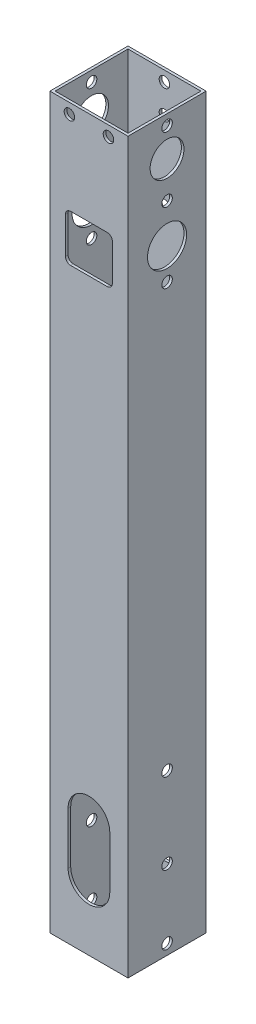
from build123d import *

# Parameters (mm, degrees)
SKETCH_1_W               = 30
SKETCH_1_H               = 30
EXTRUDE_1_DEPTH          = 140
SKETCH_2_W               = 28
SKETCH_2_H               = 28
CUT_EXTRUDE_1_DEPTH      = 141
CUT_EXTRUDE_1_DEPTH_BACK = 141
SKETCH_3_R               = 2.025
CUT_EXTRUDE_2_DEPTH      = 1
CUT_EXTRUDE_2_DEPTH_BACK = 31
SKETCH_5_R               = 2.025
CUT_EXTRUDE_3_DEPTH      = 31
SKETCH_6_R               = 2.025
CUT_EXTRUDE_4_DEPTH      = 1
SKETCH_7_W               = 18
SKETCH_7_H               = 18
CUT_EXTRUDE_5_DEPTH      = 1
FILLET_1_R               = 2
SKETCH_8_R               = 2.025
CUT_EXTRUDE_6_DEPTH      = 10
SKETCH_10_R              = 7.5
SKETCH_10_R_2            = 6.5
CUT_EXTRUDE_7_DEPTH      = 1
CUT_EXTRUDE_7_DEPTH_BACK = 31
CUT_EXTRUDE_8_DEPTH      = 1
CUT_EXTRUDE_8_DEPTH_BACK = 31
CUT_EXTRUDE_START        = 29
SKETCH_12_R              = 2.025
CUT_EXTRUDE_9_DEPTH      = 10


with BuildPart() as part:
    # 草图1 → 凸台-拉伸1 (new body, symmetric)
    with BuildSketch(Plane(origin=(0, 0, 0), x_dir=(1, 0, 0), z_dir=(0, 1, 0))):
        Rectangle(SKETCH_1_W, SKETCH_1_H)
    extrude(amount=EXTRUDE_1_DEPTH, both=True)

    # 草图2 → 切除-拉伸1 (cut, two sides)
    with BuildSketch(Plane(origin=(0, 0, 0), x_dir=(1, 0, 0), z_dir=(0, 1, 0))) as cut_extrude_1_sk:
        Rectangle(SKETCH_2_W, SKETCH_2_H)
    extrude(amount=CUT_EXTRUDE_1_DEPTH, mode=Mode.SUBTRACT)
    extrude(cut_extrude_1_sk.sketch, amount=-CUT_EXTRUDE_1_DEPTH_BACK, mode=Mode.SUBTRACT)

    # 草图3 → 切除-拉伸2 (cut, two sides)
    with BuildSketch(Plane.ZY.offset(15)) as cut_extrude_2_sk:
        with Locations((0, -78.5)):
            Circle(SKETCH_3_R)
        with Locations((0, -109.5)):
            Circle(SKETCH_3_R)
        with Locations((0, -136)):
            Circle(SKETCH_3_R)
    extrude(amount=CUT_EXTRUDE_2_DEPTH, mode=Mode.SUBTRACT)
    extrude(cut_extrude_2_sk.sketch, amount=-CUT_EXTRUDE_2_DEPTH_BACK, mode=Mode.SUBTRACT)

    # 草图5 → 切除-拉伸3 (cut, through all)
    with BuildSketch(Plane.ZY.offset(15)):
        with Locations((0, 136)):
            Circle(SKETCH_5_R)
        with Locations((0, 111)):
            Circle(SKETCH_5_R)
        with Locations((0, 84)):
            Circle(SKETCH_5_R)
    extrude(amount=-CUT_EXTRUDE_3_DEPTH, mode=Mode.SUBTRACT)

    # 草图6 → 切除-拉伸4 (cut)
    with BuildSketch(Plane(origin=(0, 0, -15), x_dir=(-1, 0, 0), z_dir=(0, 0, -1))):
        with Locations((0, 95)):
            Circle(SKETCH_6_R)
        with Locations((0, 125)):
            Circle(SKETCH_6_R)
    extrude(amount=-CUT_EXTRUDE_4_DEPTH, mode=Mode.SUBTRACT)

    # 草图7 → 切除-拉伸5 (cut)
    with BuildSketch(Plane(origin=(0, 0, 14), x_dir=(-1, 0, 0), z_dir=(0, 0, -1))):
        with Locations((0, 95)):
            Rectangle(SKETCH_7_W, SKETCH_7_H)
    extrude(amount=-CUT_EXTRUDE_5_DEPTH, mode=Mode.SUBTRACT)

    # 圆角1
    fillet_1_edges = [part.edges().sort_by_distance(p)[0] for p in [
        (-9, 104, 14.5),
        (-9, 86, 14.5),
        (9, 86, 14.5),
        (9, 104, 14.5),
    ]]
    fillet(fillet_1_edges, radius=FILLET_1_R)

    # 草图8 → 切除-拉伸6 (cut)
    with BuildSketch(Plane(origin=(0, 0, -15), x_dir=(-1, 0, 0), z_dir=(0, 0, -1))):
        with Locations((0, 136)):
            Circle(SKETCH_8_R)
    extrude(amount=-CUT_EXTRUDE_6_DEPTH, mode=Mode.SUBTRACT)

    # 草图10 → 切除-拉伸7 (cut, two sides)
    with BuildSketch(Plane.ZY.offset(15)) as cut_extrude_7_sk:
        with Locations((0, 96)):
            Circle(SKETCH_10_R)
        with Locations((0, 125)):
            Circle(SKETCH_10_R_2)
    extrude(amount=CUT_EXTRUDE_7_DEPTH, mode=Mode.SUBTRACT)
    extrude(cut_extrude_7_sk.sketch, amount=-CUT_EXTRUDE_7_DEPTH_BACK, mode=Mode.SUBTRACT)

    # 草图11 → 切除-拉伸8 (cut, two sides)
    with BuildSketch(Plane(origin=(0, 0, -15), x_dir=(-1, 0, 0), z_dir=(0, 0, -1))) as cut_extrude_8_sk:
        with BuildLine():
            Line((-8, -115), (-8, -95))
            ThreePointArc((-8, -95), (0, -87), (8, -95))
            Line((8, -95), (8, -115))
            ThreePointArc((8, -115), (0, -123), (-8, -115))
        make_face()
    extrude(amount=CUT_EXTRUDE_8_DEPTH, mode=Mode.SUBTRACT)
    extrude(cut_extrude_8_sk.sketch, amount=-CUT_EXTRUDE_8_DEPTH_BACK, mode=Mode.SUBTRACT)

    # 草图12 → 切除-拉伸9 (cut)
    with BuildSketch(Plane.XY.offset(-14).offset(CUT_EXTRUDE_START)):
        with Locations((-7.5, 136)):
            Circle(SKETCH_12_R)
        with Locations((7.5, 136)):
            Circle(SKETCH_12_R)
    extrude(amount=-CUT_EXTRUDE_9_DEPTH, mode=Mode.SUBTRACT)


solid = part.part
